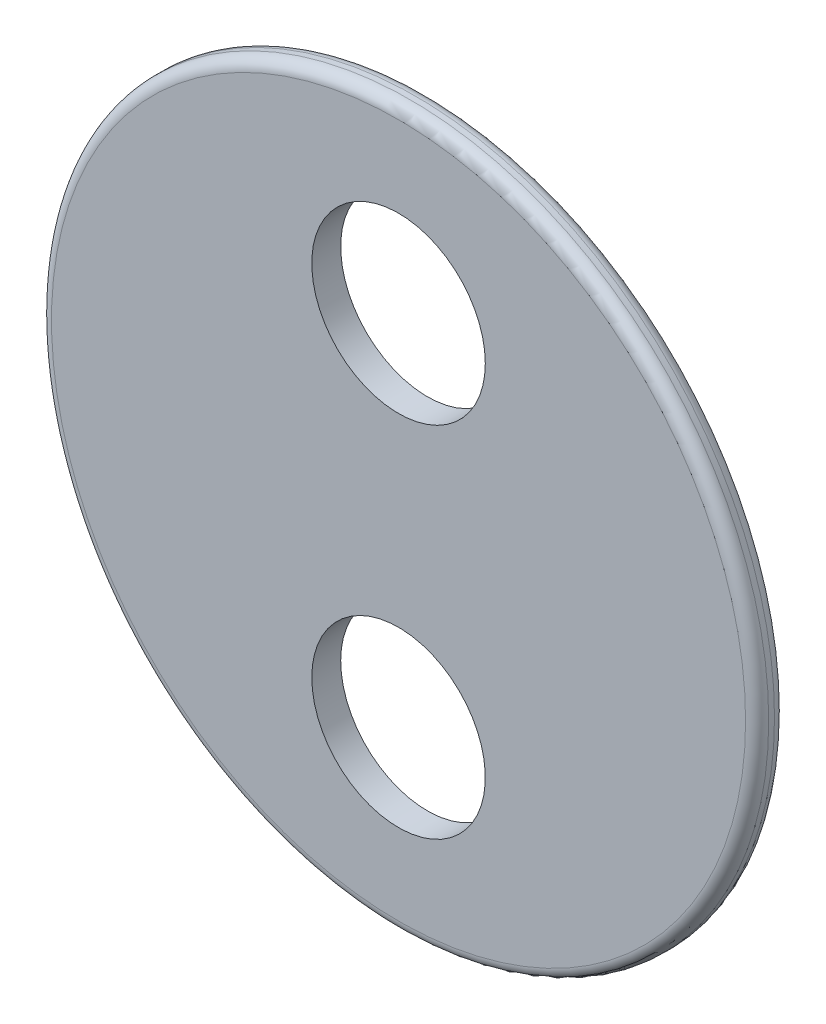
from build123d import *

# Parameters (mm, degrees)
SKETCH2_R           = 39.37
SKETCH2_R_2         = 9.525
BOSS_EXTRUDE2_DEPTH = 3.175
FILLET1_R           = 1.27


with BuildPart() as part:
    # Sketch2 → Boss-Extrude2 (new body)
    with BuildSketch(Plane.XY):
        Circle(SKETCH2_R)
        with Locations((0, 19.685)):
            Circle(SKETCH2_R_2, mode=Mode.SUBTRACT)
        with Locations((0, -19.685)):
            Circle(SKETCH2_R_2, mode=Mode.SUBTRACT)
    extrude(amount=BOSS_EXTRUDE2_DEPTH)

    # Fillet1
    fillet1_edges = [part.edges().sort_by_distance(p)[0] for p in [
        (-39.37, 0, 0),
        (-39.37, 0, 3.175),
    ]]
    fillet(fillet1_edges, radius=FILLET1_R)


solid = part.part
